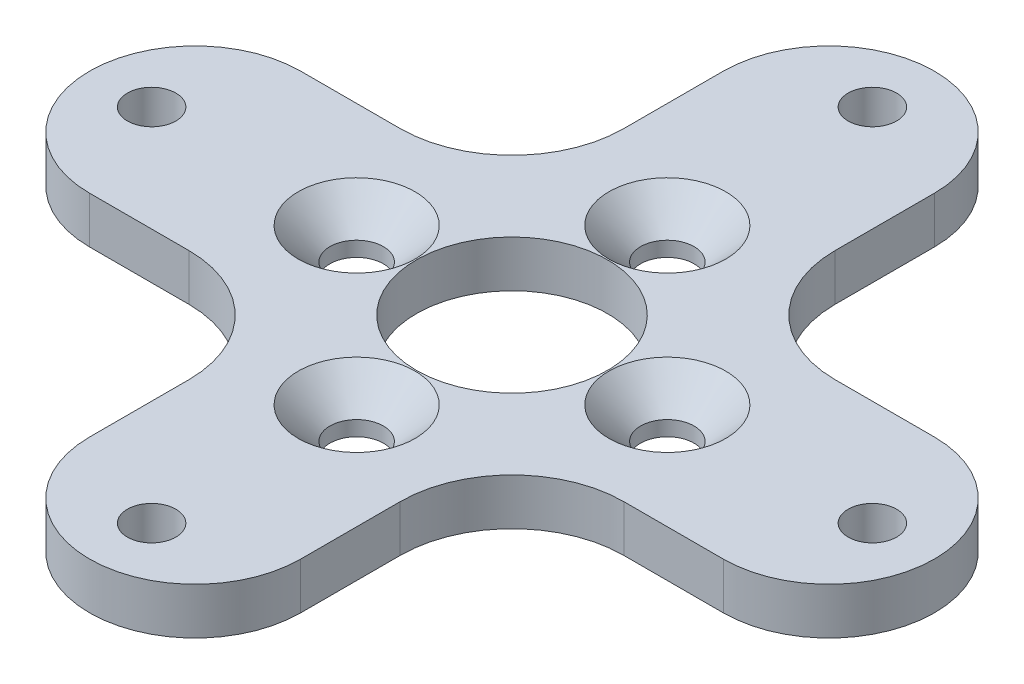
from build123d import *

# Parameters (mm, degrees)
SKETCH1_R                                      = 7.7
SKETCH1_R_2                                    = 1.95
BOSS_EXTRUDE1_DEPTH                            = 3.75
FILLET1_R                                      = 9
CSK_FOR_M4_FLAT_HEAD_MACHINE_SCREW1_AT_2_COUNT = 2
CSK_FOR_M4_FLAT_HEAD_MACHINE_SCREW1_AT_2_PITCH = 17.67766953
CSK_FOR_M4_FLAT_HEAD_MACHINE_SCREW1_AT_3_COUNT = 2
CSK_FOR_M4_FLAT_HEAD_MACHINE_SCREW1_AT_3_PITCH = 17.67766953
CSK_FOR_M4_FLAT_HEAD_MACHINE_SCREW1_AT_4_COUNT = 2
CSK_FOR_M4_FLAT_HEAD_MACHINE_SCREW1_AT_4_PITCH = 25


with BuildPart() as part:
    # Sketch1 → Boss-Extrude1 (new body)
    with BuildSketch(Plane(origin=(0, 0, 0), x_dir=(1, 0, 0), z_dir=(0, 1, 0))):
        with BuildLine():
            Line((-8.5, 25.5), (-8.5, 8.5))
            Line((-8.5, 8.5), (-25.5, 8.5))
            ThreePointArc((-25.5, 8.5), (-34, 0), (-25.5, -8.5))
            Line((-25.5, -8.5), (-8.5, -8.5))
            Line((-8.5, -8.5), (-8.5, -25.5))
            ThreePointArc((-8.5, -25.5), (0, -34), (8.5, -25.5))
            Line((8.5, -25.5), (8.5, -8.5))
            Line((8.5, -8.5), (25.5, -8.5))
            ThreePointArc((25.5, -8.5), (34, 0), (25.5, 8.5))
            Line((25.5, 8.5), (8.5, 8.5))
            Line((8.5, 8.5), (8.5, 25.5))
            ThreePointArc((8.5, 25.5), (0, 34), (-8.5, 25.5))
        make_face()
        Circle(SKETCH1_R, mode=Mode.SUBTRACT)
        with Locations((0, 29)):
            Circle(SKETCH1_R_2, mode=Mode.SUBTRACT)
        with Locations((29, 0)):
            Circle(SKETCH1_R_2, mode=Mode.SUBTRACT)
        with Locations((0, -29)):
            Circle(SKETCH1_R_2, mode=Mode.SUBTRACT)
        with Locations((-29, 0)):
            Circle(SKETCH1_R_2, mode=Mode.SUBTRACT)
    extrude(amount=BOSS_EXTRUDE1_DEPTH)

    # Fillet1
    fillet1_edges = [part.edges().sort_by_distance(p)[0] for p in [
        (-8.5, 1.875, -8.5),
        (8.5, 1.875, -8.5),
        (8.5, 1.875, 8.5),
        (-8.5, 1.875, 8.5),
    ]]
    fillet(fillet1_edges, radius=FILLET1_R)

    # Sketch3 → CSK for M4 Flat Head Machine Screw1 (revolve, cut)
    with BuildSketch(Plane(origin=(12.5, 3.75, 0), x_dir=(0, 0, 1), z_dir=(1, 0, 0))):
        Polygon((0, 0), (0, 3.75), (2.15, 3.75), (2.15, 2.55), (4.7, 0), align=None)
    csk_for_m4_flat_head_machine_screw1 = revolve(axis=Axis((12.5, 10.1, 0), (0, -1, 0)), mode=Mode.SUBTRACT)

    # CSK for M4 Flat Head Machine Screw1 at 2: CSK for M4 Flat Head Machine Screw1 ×2
    with Locations(*[Vector(-0.707106781, 0, -0.707106781) * (i * CSK_FOR_M4_FLAT_HEAD_MACHINE_SCREW1_AT_2_PITCH) for i in range(1, CSK_FOR_M4_FLAT_HEAD_MACHINE_SCREW1_AT_2_COUNT)]):
        add(csk_for_m4_flat_head_machine_screw1, mode=Mode.SUBTRACT)

    # CSK for M4 Flat Head Machine Screw1 at 3: CSK for M4 Flat Head Machine Screw1 ×2
    with Locations(*[Vector(-0.707106781, 0, 0.707106781) * (i * CSK_FOR_M4_FLAT_HEAD_MACHINE_SCREW1_AT_3_PITCH) for i in range(1, CSK_FOR_M4_FLAT_HEAD_MACHINE_SCREW1_AT_3_COUNT)]):
        add(csk_for_m4_flat_head_machine_screw1, mode=Mode.SUBTRACT)

    # CSK for M4 Flat Head Machine Screw1 at 4: CSK for M4 Flat Head Machine Screw1 ×2
    with Locations(*[(-i * CSK_FOR_M4_FLAT_HEAD_MACHINE_SCREW1_AT_4_PITCH, 0, 0) for i in range(1, CSK_FOR_M4_FLAT_HEAD_MACHINE_SCREW1_AT_4_COUNT)]):
        add(csk_for_m4_flat_head_machine_screw1, mode=Mode.SUBTRACT)


solid = part.part
